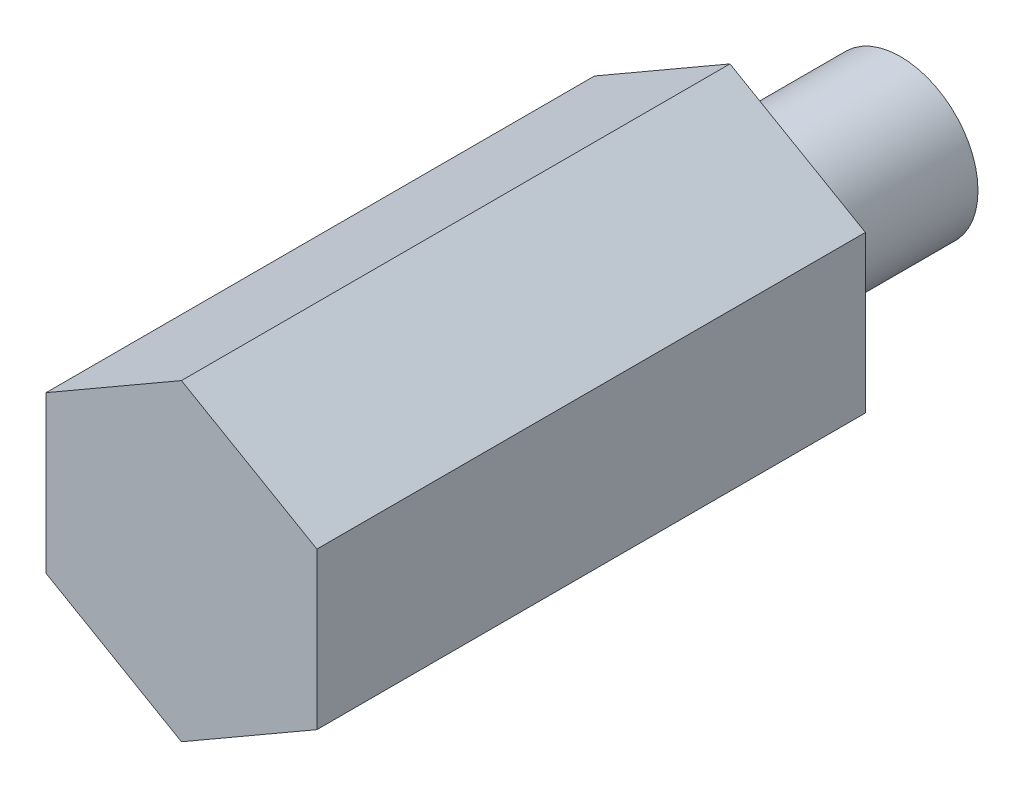
from build123d import *

# Parameters (mm, degrees)
BOSS_EXTRUDE2_DEPTH      = 11.25
BOSS_EXTRUDE2_DEPTH_BACK = 11.25
SKETCH4_R                = 3.175
BOSS_EXTRUDE3_DEPTH      = 7.0000114


with BuildPart() as part:
    # Sketch3 → Boss-Extrude2 (new body, two sides)
    with BuildSketch(Plane.XY) as boss_extrude2_sk:
        Polygon((-5.55625, -3.207902433), (0, -6.415804866), (5.55625, -3.207902433), (5.55625, 3.207902433), (0, 6.415804866), (-5.55625, 3.207902433), align=None)
    extrude(amount=BOSS_EXTRUDE2_DEPTH)
    extrude(boss_extrude2_sk.sketch, amount=-BOSS_EXTRUDE2_DEPTH_BACK)

    # Sketch4 → Boss-Extrude3 (add)
    with BuildSketch(Plane.XY.offset(-11.25)):
        Circle(SKETCH4_R)
    extrude(amount=-BOSS_EXTRUDE3_DEPTH)


solid = part.part
